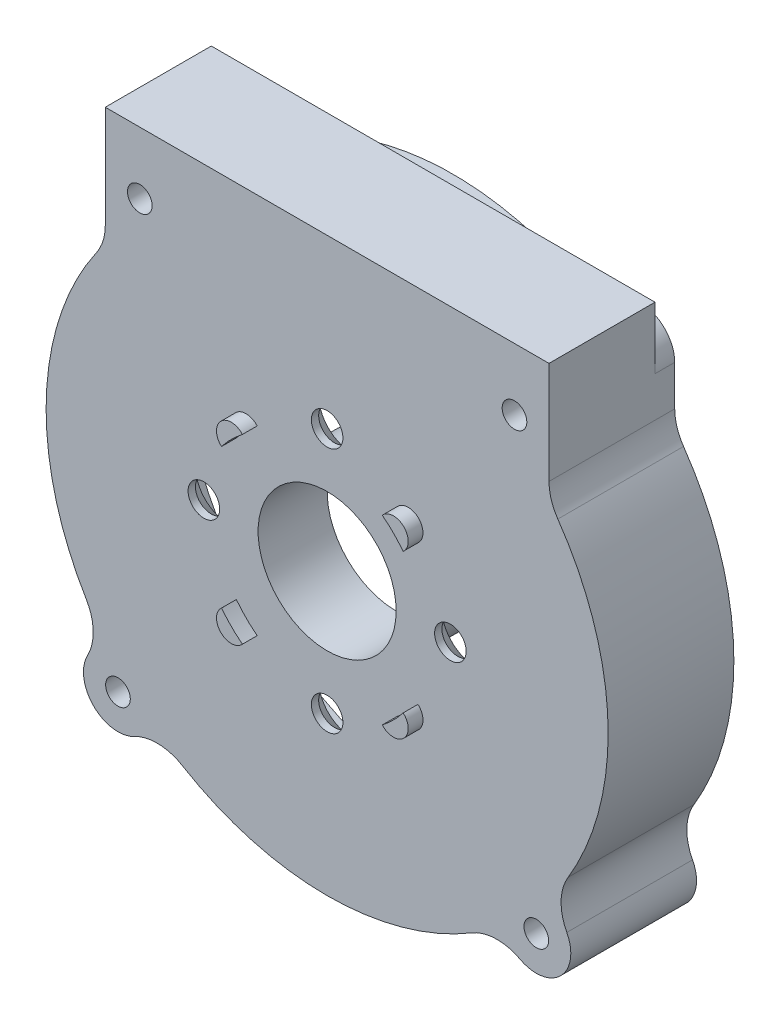
from build123d import *

# Parameters (mm, degrees)
CSK_FOR_M3_SFHCS1_AT_2_COUNT = 2
CSK_FOR_M3_SFHCS1_AT_2_PITCH = 17.67766953
CSK_FOR_M3_SFHCS1_AT_3_COUNT = 2
CSK_FOR_M3_SFHCS1_AT_3_PITCH = 25
CSK_FOR_M3_SFHCS1_AT_4_COUNT = 2
CSK_FOR_M3_SFHCS1_AT_4_PITCH = 17.67766953
BOSS_EXTRUDE3_DEPTH          = 10.75
BOSS_EXTRUDE7_DEPTH          = 2
FILLET6_R                    = 5
SKETCH14_R                   = 1.25
CUT_EXTRUDE2_DEPTH           = 13.75
BOSS_EXTRUDE8_DEPTH          = 12.75
SKETCH16_R                   = 1.25
CUT_EXTRUDE3_DEPTH           = 13.75
FILLET8_R                    = 5
SKETCH17_R                   = 1.5
BOSS_EXTRUDE9_DEPTH          = 1.5
SKETCH20_R                   = 11.625
CUT_EXTRUDE4_DEPTH           = 1.5


with BuildPart() as part:
    # Sketch1 → Revolve1 (revolve)
    with BuildSketch(Plane(origin=(0, 0, 0), x_dir=(0, 0, -1), z_dir=(1, 0, 0))):
        Polygon((5.929940933, 28.5), (-0.458333333, 28.5), (-0.458333333, 17.5), (-0.458333333, 7), (6.541666667, 7), (6.541666667, 8.5), (2.541666667, 8.5), (2.541666667, 9), (2.041666667, 9), (2.041666667, 15), (2.041666667, 26.5), (6.791666667, 26.5), (6.791666667, 27.5), (12.291666667, 27.5), (12.291666667, 28.5), align=None)
    revolve(axis=Axis((0, 0, 0), (0, 0, -1)))

    # Sketch3 → CSK for M3 SFHCS1 (revolve, cut)
    with BuildSketch(Plane(origin=(0, 12.5, -2.041666667), x_dir=(0, 1, 0), z_dir=(1, 0, 0))):
        Polygon((0, 0), (0, 2.5), (1.6, 2.5), (1.6, 1.76), (3.36, 0), align=None)
    csk_for_m3_sfhcs1 = revolve(axis=Axis((0, 12.5, -8.391666667), (0, 0, 1)), mode=Mode.SUBTRACT)

    # CSK for M3 SFHCS1 at 2: CSK for M3 SFHCS1 ×2
    with Locations(*[Vector(-0.707106781, -0.707106781, 0) * (i * CSK_FOR_M3_SFHCS1_AT_2_PITCH) for i in range(1, CSK_FOR_M3_SFHCS1_AT_2_COUNT)]):
        add(csk_for_m3_sfhcs1, mode=Mode.SUBTRACT)

    # CSK for M3 SFHCS1 at 3: CSK for M3 SFHCS1 ×2
    with Locations(*[(0, -i * CSK_FOR_M3_SFHCS1_AT_3_PITCH, 0) for i in range(1, CSK_FOR_M3_SFHCS1_AT_3_COUNT)]):
        add(csk_for_m3_sfhcs1, mode=Mode.SUBTRACT)

    # CSK for M3 SFHCS1 at 4: CSK for M3 SFHCS1 ×2
    with Locations(*[Vector(0.707106781, -0.707106781, 0) * (i * CSK_FOR_M3_SFHCS1_AT_4_PITCH) for i in range(1, CSK_FOR_M3_SFHCS1_AT_4_COUNT)]):
        add(csk_for_m3_sfhcs1, mode=Mode.SUBTRACT)

    # Sketch11 → Boss-Extrude3 (add)
    with BuildSketch(Plane.XY.offset(0.458333333)):
        with BuildLine():
            Line((-22.5, 29.5), (-22.5, 17.492855685))
            ThreePointArc((-22.5, 17.492855685), (0, 28.5), (22.5, 17.492855685))
            Line((22.5, 17.492855685), (22.5, 29.5))
            Line((22.5, 29.5), (-22.5, 29.5))
        make_face()
    extrude(amount=-BOSS_EXTRUDE3_DEPTH)

    # Sketch12 → Boss-Extrude7 (add)
    with BuildSketch(Plane(origin=(0, 0, -10.291666667), x_dir=(-1, 0, 0), z_dir=(0, 0, -1))):
        with BuildLine():
            ThreePointArc((-18.04999995, 22.055554897), (-19.216219586, 21.047254092), (-20.326210311, 19.977366553))
            ThreePointArc((-20.326210311, 19.977366553), (-19.921854076, 19.839957524), (-19.503772735, 19.752818562))
            ThreePointArc((-19.503772735, 19.752818562), (-17.580801654, 21.482234642), (-15.505225986, 23.02518098))
            ThreePointArc((-15.505225986, 23.02518098), (-15.50130674, 23.120741552), (-15.5, 23.216373532))
            ThreePointArc((-15.5, 23.216373532), (-15.515704879, 23.547564583), (-15.562678578, 23.875783453))
            ThreePointArc((-15.562678578, 23.875783453), (-16.830963949, 22.999318523), (-18.04999995, 22.055554897))
        make_face()
        with BuildLine():
            ThreePointArc((-19, 26.716373532), (-21.474873734, 25.691247267), (-22.5, 23.216373532))
            ThreePointArc((-22.5, 23.216373532), (-21.906177566, 21.265955127), (-20.326210311, 19.977366553))
            ThreePointArc((-20.326210311, 19.977366553), (-19.216219586, 21.047254092), (-18.04999995, 22.055554897))
            ThreePointArc((-18.04999995, 22.055554897), (-16.830963949, 22.999318523), (-15.562678578, 23.875783453))
            ThreePointArc((-15.562678578, 23.875783453), (-16.77041873, 25.914329677), (-19, 26.716373532))
        make_face()
        with BuildLine():
            ThreePointArc((-17.5, 23.216373532), (-17.644455815, 22.574111933), (-18.04999995, 22.055554897))
            ThreePointArc((-18.04999995, 22.055554897), (-20.355544185, 23.858635132), (-17.5, 23.216373532))
        make_face(mode=Mode.SUBTRACT)
        with BuildLine():
            ThreePointArc((-20.326210311, 19.977366553), (-21.906177566, 21.265955127), (-22.5, 23.216373532))
            Line((-22.5, 23.216373532), (-22.5, 17.492855685))
            ThreePointArc((-22.5, 17.492855685), (-21.449108862, 18.766612082), (-20.326210311, 19.977366553))
        make_face()
        with BuildLine():
            ThreePointArc((18.049999991, 22.055554863), (16.830963971, 22.999318508), (15.562678578, 23.875783453))
            ThreePointArc((15.562678578, 23.875783453), (15.507956483, 23.452238061), (15.505225986, 23.02518098))
            ThreePointArc((15.505225986, 23.02518098), (17.580801654, 21.482234642), (19.503772735, 19.752818562))
            ThreePointArc((19.503772735, 19.752818562), (19.921854076, 19.839957524), (20.326210311, 19.977366553))
            ThreePointArc((20.326210311, 19.977366553), (19.216219606, 21.047254074), (18.049999991, 22.055554863))
        make_face()
        with BuildLine():
            ThreePointArc((22.5, 23.216373532), (21.474873734, 25.691247267), (19, 26.716373532))
            ThreePointArc((19, 26.716373532), (16.77041873, 25.914329677), (15.562678578, 23.875783453))
            ThreePointArc((15.562678578, 23.875783453), (16.830963971, 22.999318508), (18.049999991, 22.055554863))
            ThreePointArc((18.049999991, 22.055554863), (19.216219606, 21.047254074), (20.326210311, 19.977366553))
            ThreePointArc((20.326210311, 19.977366553), (21.906177566, 21.265955127), (22.5, 23.216373532))
        make_face()
        with BuildLine():
            ThreePointArc((20.5, 23.216373532), (19.642261624, 21.860829359), (18.049999991, 22.055554863))
            ThreePointArc((18.049999991, 22.055554863), (18.357738376, 24.571917706), (20.5, 23.216373532))
        make_face(mode=Mode.SUBTRACT)
        with BuildLine():
            ThreePointArc((20.326210311, 19.977366553), (21.449108862, 18.766612082), (22.5, 17.492855685))
            Line((22.5, 17.492855685), (22.5, 23.216373532))
            ThreePointArc((22.5, 23.216373532), (21.906177566, 21.265955127), (20.326210311, 19.977366553))
        make_face()
    extrude(amount=BOSS_EXTRUDE7_DEPTH)

    # Fillet6
    fillet6_edges = [part.edges().sort_by_distance(p)[0] for p in [
        (-15.562678578, 23.875783453, -11.291666667),
        (22.5, 17.492855685, -5.916666667),
        (-22.5, 17.492855685, -5.916666667),
        (15.562678578, 23.875783453, -11.291666667),
    ]]
    fillet(fillet6_edges, radius=FILLET6_R)

    # Sketch14 → Cut-Extrude2 (cut, through all)
    with BuildSketch(Plane(origin=(0, 0, -12.291666667), x_dir=(-1, 0, 0), z_dir=(0, 0, -1))):
        with Locations((-19, 23.216373532)):
            Circle(SKETCH14_R)
        with Locations((19, 23.216373532)):
            Circle(SKETCH14_R)
    extrude(amount=-CUT_EXTRUDE2_DEPTH, mode=Mode.SUBTRACT)

    # Sketch15 → Boss-Extrude8 (add)
    with BuildSketch(Plane.XY.offset(0.458333333)):
        with BuildLine():
            ThreePointArc((17.858431324, -22.210952943), (21.717335169, -24.676706171), (24.713203436, -21.213203436))
            ThreePointArc((24.713203436, -21.213203436), (24.018744674, -19.120612133), (22.210952943, -17.858431324))
            ThreePointArc((22.210952943, -17.858431324), (20.152543264, -20.152543264), (17.858431324, -22.210952943))
        make_face()
        with BuildLine():
            ThreePointArc((-22.210952943, -17.858431324), (-23.68807717, -23.68807717), (-17.858431324, -22.210952943))
            ThreePointArc((-17.858431324, -22.210952943), (-20.152543264, -20.152543264), (-22.210952943, -17.858431324))
        make_face()
    extrude(amount=-BOSS_EXTRUDE8_DEPTH)

    # Sketch16 → Cut-Extrude3 (cut, through all)
    with BuildSketch(Plane(origin=(0, 0, -12.291666667), x_dir=(-1, 0, 0), z_dir=(0, 0, -1))):
        with Locations((-21.213203436, -21.213203436)):
            Circle(SKETCH16_R)
        with Locations((21.213203436, -21.213203436)):
            Circle(SKETCH16_R)
    extrude(amount=-CUT_EXTRUDE3_DEPTH, mode=Mode.SUBTRACT)

    # Fillet8
    fillet8_edges = [part.edges().sort_by_distance(p)[0] for p in [
        (17.858431324, -22.210952943, -5.916666667),
        (22.210952943, -17.858431324, -5.916666667),
        (-22.210952943, -17.858431324, -5.916666667),
        (-17.858431324, -22.210952943, -5.916666667),
    ]]
    fillet(fillet8_edges, radius=FILLET8_R)

    # Sketch17 → Boss-Extrude9 (add)
    with BuildSketch(Plane.XY.offset(0.458333333)):
        with Locations((8.220116331, 8.220116331)):
            Circle(SKETCH17_R)
        with Locations((8.220116331, -8.220116331)):
            Circle(SKETCH17_R)
        with Locations((-8.220116331, -8.220116331)):
            Circle(SKETCH17_R)
        with Locations((-8.220116331, 8.220116331)):
            Circle(SKETCH17_R)
    extrude(amount=BOSS_EXTRUDE9_DEPTH)

    # Sketch20 → Cut-Extrude4 (cut)
    with BuildSketch(Plane.XY.offset(1.958333333)):
        Circle(SKETCH20_R)
    extrude(amount=-CUT_EXTRUDE4_DEPTH, mode=Mode.SUBTRACT)


solid = part.part
